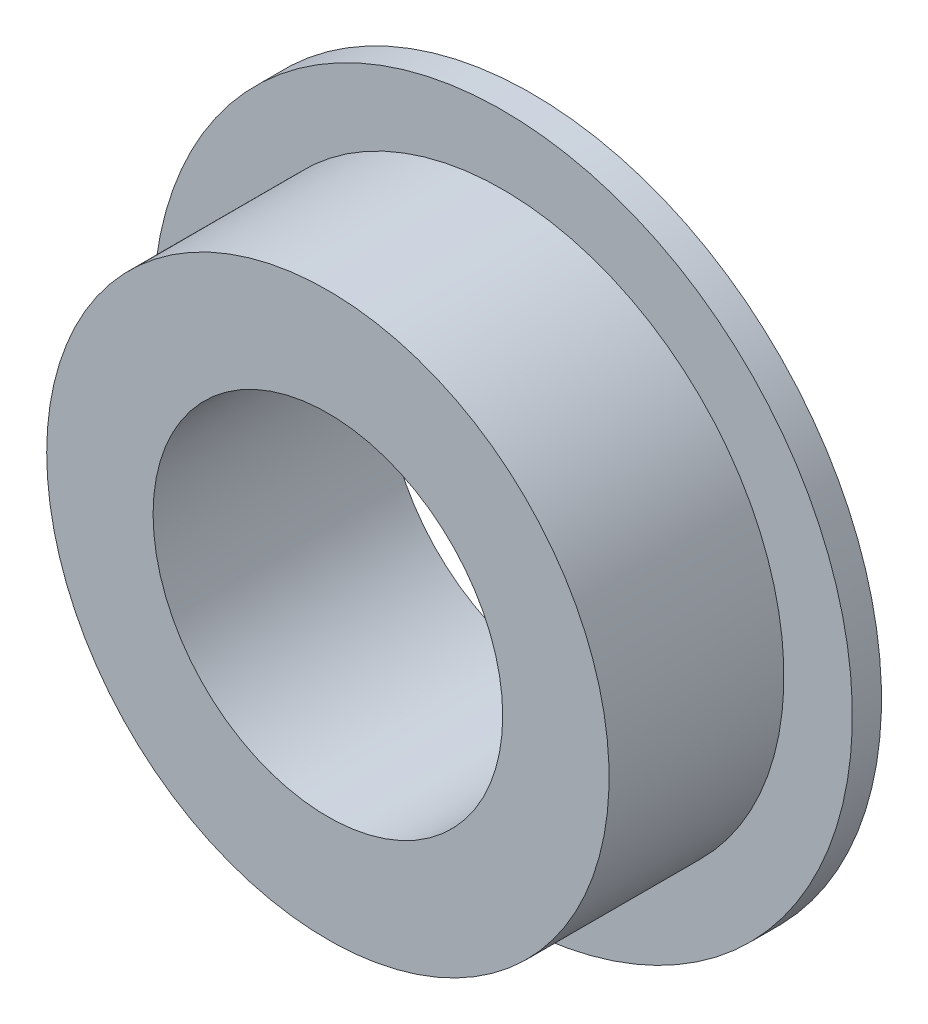
from build123d import *

# Parameters (mm, degrees)
SKETCH1_R           = 19.05
SKETCH1_R_2         = 9.525
BOSS_EXTRUDE1_DEPTH = 12.7
SKETCH2_W           = 9.525
SKETCH2_H           = 3.729002221
SKETCH2_W_2         = 1.5875
SKETCH2_H_2         = 6.35


with BuildPart() as part:
    # Sketch1 → Boss-Extrude1 (new body)
    with BuildSketch(Plane.XY):
        Circle(SKETCH1_R)
        Circle(SKETCH1_R_2, mode=Mode.SUBTRACT)
    extrude(amount=BOSS_EXTRUDE1_DEPTH)

    # Sketch2 → Cut-Revolve1 (revolve, cut)
    with BuildSketch(Plane(origin=(0, 0, 0), x_dir=(0, 0, -1), z_dir=(1, 0, 0))):
        with Locations((-7.9375, 17.185498889)):
            Rectangle(SKETCH2_W, SKETCH2_H)
        with Locations((-0.79375, 15.875)):
            Rectangle(SKETCH2_W_2, SKETCH2_H_2)
    revolve(axis=Axis((0, 0, 0), (0, 0, 1)), mode=Mode.SUBTRACT)


solid = part.part
